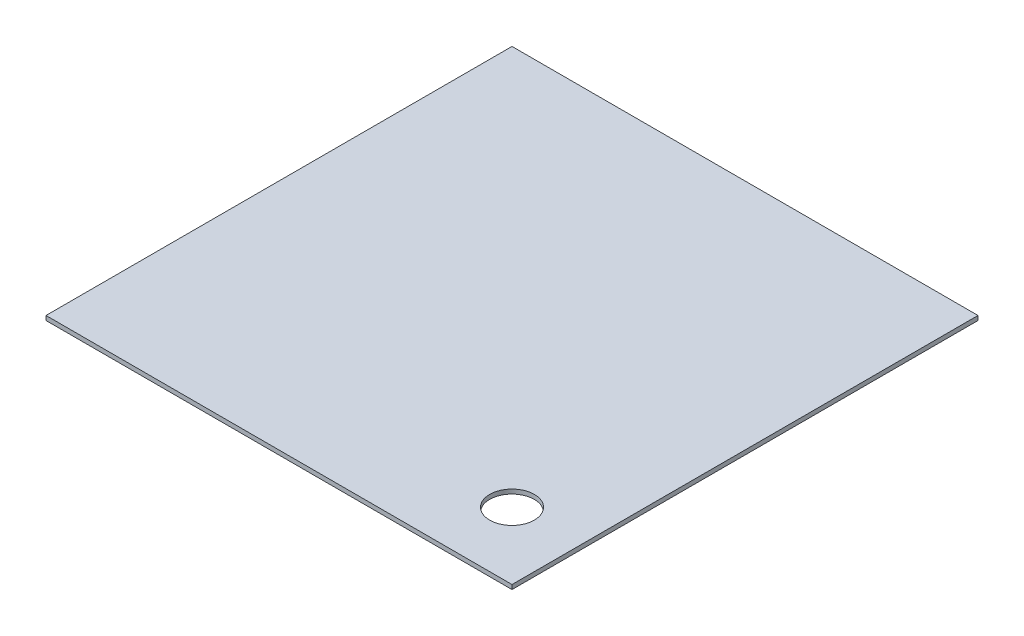
from build123d import *

# Parameters (mm, degrees)
SKETCH1_W           = 265.3284
SKETCH1_H           = 265.3284
BOSS_EXTRUDE1_DEPTH = 2.5
SKETCH2_R           = 12.7
CUT_EXTRUDE1_DEPTH  = 3.5


with BuildPart() as part:
    # Sketch1 → Boss-Extrude1 (new body)
    with BuildSketch(Plane(origin=(0, 0, 0), x_dir=(1, 0, 0), z_dir=(0, 1, 0))):
        Rectangle(SKETCH1_W, SKETCH1_H)
    extrude(amount=BOSS_EXTRUDE1_DEPTH)

    # Sketch2 → Cut-Extrude1 (cut, through all)
    with BuildSketch(Plane(origin=(0, 2.5, 0), x_dir=(1, 0, 0), z_dir=(0, 1, 0))):
        with Locations((94.5642, -94.5642)):
            Circle(SKETCH2_R)
    extrude(amount=-CUT_EXTRUDE1_DEPTH, mode=Mode.SUBTRACT)


solid = part.part
